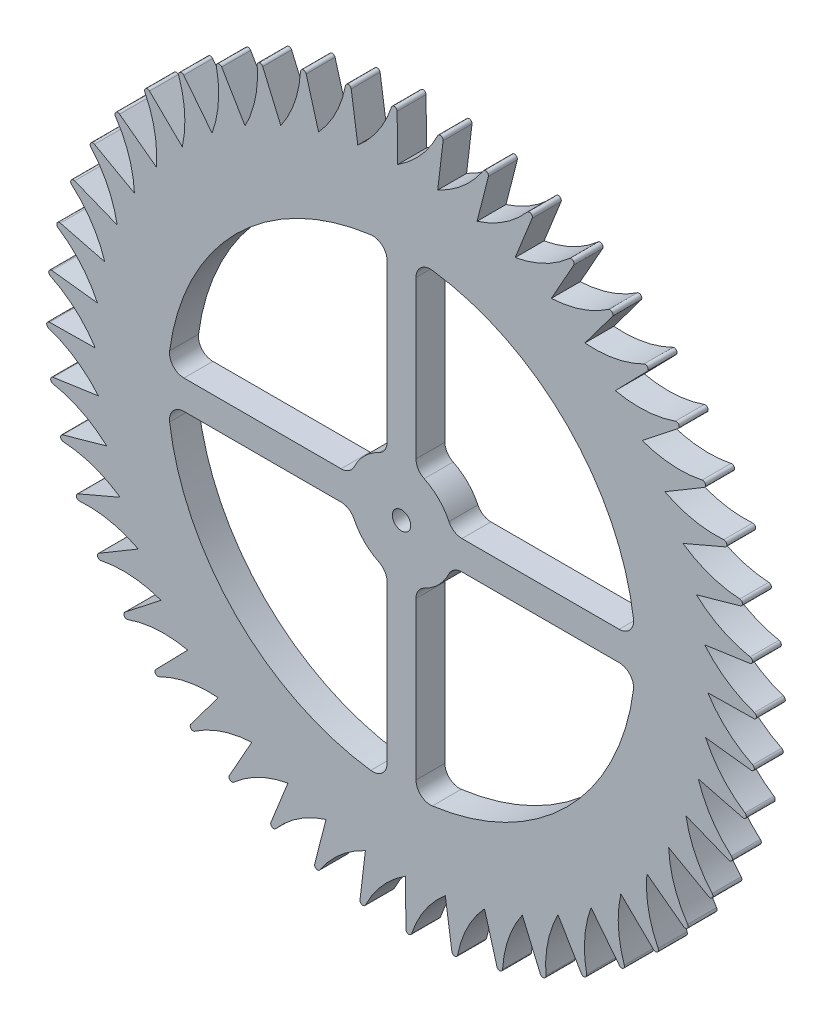
from build123d import *

# Parameters (mm, degrees)
SKETCH1_R           = 1.5875
BOSS_EXTRUDE1_DEPTH = 5
CUT_EXTRUDE1_DEPTH  = 6


with BuildPart() as part:
    # Sketch1 → Boss-Extrude1 (new body)
    with BuildSketch(Plane.XY):
        with BuildLine():
            Line((48.619657043, 86.443168783), (48.520234559, 94.35939249))
            ThreePointArc((48.520234559, 94.35939249), (48.096628031, 94.847248989), (47.545526606, 94.510004756))
            ThreePointArc((47.545526606, 94.510004756), (45.227938091, 89.801102483), (41.713355374, 85.903322927))
            Line((41.713355374, 85.903322927), (40.581508925, 93.738845005))
            ThreePointArc((40.581508925, 93.738845005), (40.097848359, 94.167236077), (39.595480889, 93.760943844))
            ThreePointArc((39.595480889, 93.760943844), (37.912354747, 88.789820879), (34.936602096, 84.466642269))
            Line((34.936602096, 84.466642269), (32.79169789, 92.087394762))
            ThreePointArc((32.79169789, 92.087394762), (32.256258852, 92.448990516), (31.811220983, 91.980602057))
            ThreePointArc((31.811220983, 91.980602057), (30.791355971, 86.832315692), (28.405349338, 82.157708811))
            Line((28.405349338, 82.157708811), (25.284087281, 89.433298531))
            ThreePointArc((25.284087281, 89.433298531), (24.70603128, 89.721911965), (24.325937734, 89.199441536))
            ThreePointArc((24.325937734, 89.199441536), (23.986784024, 83.962080378), (22.231348645, 79.016029046))
            Line((22.231348645, 79.016029046), (18.187134395, 85.821968637))
            ThreePointArc((18.187134395, 85.821968637), (17.576352131, 86.032661494), (17.267706414, 85.465048708))
            ThreePointArc((17.267706414, 85.465048708), (17.61506702, 80.228225458), (16.520238881, 75.095357986))
            Line((16.520238881, 75.095357986), (11.622270065, 81.315195933))
            ThreePointArc((11.622270065, 81.315195933), (10.989212192, 81.444363201), (10.757295317, 80.841320071))
            ThreePointArc((10.757295317, 80.841320071), (11.785226803, 75.694638227), (11.369738717, 70.4627794))
            Line((11.369738717, 70.4627794), (5.70182094, 75.990092552))
            ThreePointArc((5.70182094, 75.990092552), (5.057319253, 76.035524142), (4.906099382, 75.407368903))
            ThreePointArc((4.906099382, 75.407368903), (6.597013556, 70.438889619), (6.867974639, 65.197557991))
            Line((6.867974639, 65.197557991), (0.527087545, 69.937772487))
            ThreePointArc((0.527087545, 69.937772487), (-0.117830353, 69.898691053), (-0.185765805, 69.256171615))
            ThreePointArc((-0.185765805, 69.256171615), (2.139199045, 64.550906948), (3.091973078, 59.389783158))
            Line((3.091973078, 59.389783158), (-3.813388996, 63.261792614))
            ThreePointArc((-3.813388996, 63.261792614), (-4.447688381, 63.13886685), (-4.431177021, 62.492976899))
            ThreePointArc((-4.431177021, 62.492976899), (-1.511942286, 58.131435232), (0.106342469, 53.138827538))
            Line((0.106342469, 53.138827538), (-7.245341926, 56.076380799))
            ThreePointArc((-7.245341926, 56.076380799), (-7.858169761, 55.871713998), (-7.757494101, 55.23350489))
            ThreePointArc((-7.757494101, 55.23350489), (-4.293938399, 51.290313412), (-2.037832222, 46.551646715))
            Line((-2.037832222, 46.551646715), (-9.71004958, 48.504481431))
            ThreePointArc((-9.71004958, 48.504481431), (-10.290920209, 48.221575498), (-10.107802839, 47.601967168))
            ThreePointArc((-10.107802839, 47.601967168), (-6.159188567, 44.144594977), (-3.303863571, 39.740949179))
            Line((-3.303863571, 39.740949179), (-11.165340126, 40.675651806))
            ThreePointArc((-11.165340126, 40.675651806), (-11.704314691, 40.319347342), (-11.4418888, 39.72894146))
            ThreePointArc((-11.4418888, 39.72894146), (-7.075777843, 36.816545152), (-3.670089431, 32.823267854))
            Line((-3.670089431, 32.823267854), (-11.586313138, 32.72384537))
            ThreePointArc((-11.586313138, 32.72384537), (-12.074169637, 32.300238842), (-11.736925404, 31.749137417))
            ThreePointArc((-11.736925404, 31.749137417), (-7.028023131, 29.431548901), (-3.130243575, 25.916966184))
            Line((-3.130243575, 25.916966184), (-10.965765653, 24.785119736))
            ThreePointArc((-10.965765653, 24.785119736), (-11.394156725, 24.30145917), (-10.987864492, 23.799091699))
            ThreePointArc((-10.987864492, 23.799091699), (-6.016741527, 22.115965558), (-1.693562916, 19.140212907))
            Line((-1.693562916, 19.140212907), (-9.314315409, 16.995308701))
            ThreePointArc((-9.314315409, 16.995308701), (-9.675911164, 16.459869663), (-9.207522705, 16.014831793))
            ThreePointArc((-9.207522705, 16.014831793), (-4.05923634, 14.994966781), (0.615370541, 12.608960149))
            Line((0.615370541, 12.608960149), (-6.660219179, 9.487698091))
            ThreePointArc((-6.660219179, 9.487698091), (-6.948832613, 8.909642091), (-6.426362184, 8.529548545))
            ThreePointArc((-6.426362184, 8.529548545), (-1.189001025, 8.190394835), (3.757050306, 6.434959456))
            Line((3.757050306, 6.434959456), (-3.048889284, 2.390745206))
            ThreePointArc((-3.048889284, 2.390745206), (-3.259582142, 1.779962942), (-2.691969356, 1.471317224))
            ThreePointArc((-2.691969356, 1.471317224), (2.544853894, 1.818677831), (7.677721366, 0.723849692))
            Line((7.677721366, 0.723849692), (1.457883419, -4.174119124))
            ThreePointArc((1.457883419, -4.174119124), (1.328716151, -4.807176997), (1.931759281, -5.039093873))
            ThreePointArc((1.931759281, -5.039093873), (7.078441125, -4.011162386), (12.310299952, -4.426650472))
            Line((12.310299952, -4.426650472), (6.7829868, -10.09456825))
            ThreePointArc((6.7829868, -10.09456825), (6.73755521, -10.739069936), (7.365710449, -10.890289807))
            ThreePointArc((7.365710449, -10.890289807), (12.334189733, -9.199375634), (17.575521361, -8.92841455))
            Line((17.575521361, -8.92841455), (12.835306865, -15.269301644))
            ThreePointArc((12.835306865, -15.269301644), (12.874388299, -15.914219542), (13.516907737, -15.982154995))
            ThreePointArc((13.516907737, -15.982154995), (18.222172404, -13.657190144), (23.383296194, -12.704416111))
            Line((23.383296194, -12.704416111), (19.511286738, -19.609778185))
            ThreePointArc((19.511286738, -19.609778185), (19.634212503, -20.244077571), (20.280102453, -20.22756621))
            ThreePointArc((20.280102453, -20.22756621), (24.64164412, -17.308331476), (29.634251814, -15.690046721))
            Line((29.634251814, -15.690046721), (26.696698553, -23.041731116))
            ThreePointArc((26.696698553, -23.041731116), (26.901365354, -23.65455895), (27.539574462, -23.55388329))
            ThreePointArc((27.539574462, -23.55388329), (31.482765941, -20.090327588), (36.221432637, -17.834221412))
            Line((36.221432637, -17.834221412), (34.268597922, -25.506438769))
            ThreePointArc((34.268597922, -25.506438769), (34.551503854, -26.087309398), (35.171112184, -25.904192028))
            ThreePointArc((35.171112184, -25.904192028), (38.628484375, -21.955577756), (43.032130173, -19.100252761))
            Line((43.032130173, -19.100252761), (42.097427547, -26.961729315))
            ThreePointArc((42.097427547, -26.961729315), (42.453732011, -27.500703881), (43.044137892, -27.238277989))
            ThreePointArc((43.044137892, -27.238277989), (45.9565342, -22.872167032), (49.949811498, -19.46647862))
            Line((49.949811498, -19.46647862), (50.049233982, -27.382702327))
            ThreePointArc((50.049233982, -27.382702327), (50.47284051, -27.870558826), (51.023941935, -27.533314593))
            ThreePointArc((51.023941935, -27.533314593), (53.341530451, -22.82441232), (56.856113168, -18.926632765))
            Line((56.856113168, -18.926632765), (57.987959616, -26.762154842))
            ThreePointArc((57.987959616, -26.762154842), (58.471620182, -27.190545914), (58.973987653, -26.784253681))
            ThreePointArc((58.973987653, -26.784253681), (60.657113794, -21.813130716), (63.632866445, -17.489952106))
            Line((63.632866445, -17.489952106), (65.777770651, -25.110704599))
            ThreePointArc((65.777770651, -25.110704599), (66.31320969, -25.472300354), (66.758247559, -25.003911894))
            ThreePointArc((66.758247559, -25.003911894), (67.778112571, -19.855625529), (70.164119203, -15.181018648))
            Line((70.164119203, -15.181018648), (73.285381261, -22.456608368))
            ThreePointArc((73.285381261, -22.456608368), (73.863437261, -22.745221803), (74.243530808, -22.222751373))
            ThreePointArc((74.243530808, -22.222751373), (74.582684518, -16.985390215), (76.338119896, -12.039338883))
            Line((76.338119896, -12.039338883), (80.382334147, -18.845278474))
            ThreePointArc((80.382334147, -18.845278474), (80.99311641, -19.055971331), (81.301762128, -18.488358545))
            ThreePointArc((81.301762128, -18.488358545), (80.954401522, -13.251535296), (82.04922966, -8.118667823))
            Line((82.04922966, -8.118667823), (86.947198476, -14.338505771))
            ThreePointArc((86.947198476, -14.338505771), (87.58025635, -14.467673038), (87.812173225, -13.864629908))
            ThreePointArc((87.812173225, -13.864629908), (86.784241738, -8.717948065), (87.199729824, -3.486089237))
            Line((87.199729824, -3.486089237), (92.867647602, -9.013402389))
            ThreePointArc((92.867647602, -9.013402389), (93.512149289, -9.058833979), (93.663369159, -8.43067874))
            ThreePointArc((93.663369159, -8.43067874), (91.972454986, -3.462199456), (91.701493902, 1.779132172))
            Line((91.701493902, 1.779132172), (98.042380997, -2.961082325))
            ThreePointArc((98.042380997, -2.961082325), (98.687298895, -2.92200089), (98.755234347, -2.279481452))
            ThreePointArc((98.755234347, -2.279481452), (96.430269496, 2.425783214), (95.477495463, 7.586907005))
            Line((95.477495463, 7.586907005), (102.382857538, 3.714897548))
            ThreePointArc((102.382857538, 3.714897548), (103.017156923, 3.837823313), (103.000645562, 4.483713264))
            ThreePointArc((103.000645562, 4.483713264), (100.081410828, 8.84525493), (98.463126073, 13.837862625))
            Line((98.463126073, 13.837862625), (105.814810468, 10.900309363))
            ThreePointArc((105.814810468, 10.900309363), (106.427638302, 11.104976165), (106.326962642, 11.743185273))
            ThreePointArc((106.326962642, 11.743185273), (102.86340694, 15.686376751), (100.607300764, 20.425043448))
            Line((100.607300764, 20.425043448), (108.279518122, 18.472208732))
            ThreePointArc((108.279518122, 18.472208732), (108.86038875, 18.755114664), (108.67727138, 19.374722994))
            ThreePointArc((108.67727138, 19.374722994), (104.728657108, 22.832095186), (101.873332113, 27.235740984))
            Line((101.873332113, 27.235740984), (109.734808667, 26.301038357))
            ThreePointArc((109.734808667, 26.301038357), (110.273783233, 26.657342821), (110.011357341, 27.247748703))
            ThreePointArc((110.011357341, 27.247748703), (105.645246385, 30.160145011), (102.239557972, 34.153422309))
            Line((102.239557972, 34.153422309), (110.15578168, 34.252844793))
            ThreePointArc((110.15578168, 34.252844793), (110.643638178, 34.676451321), (110.306393945, 35.227552746))
            ThreePointArc((110.306393945, 35.227552746), (105.597491673, 37.545141261), (101.699712117, 41.059723979))
            Line((101.699712117, 41.059723979), (109.535234194, 42.191570427))
            ThreePointArc((109.535234194, 42.191570427), (109.963625266, 42.675230993), (109.557333034, 43.177598464))
            ThreePointArc((109.557333034, 43.177598464), (104.586210069, 44.860724605), (100.263031458, 47.836477256))
            Line((100.263031458, 47.836477256), (107.883783951, 49.981381462))
            ThreePointArc((107.883783951, 49.981381462), (108.245379706, 50.5168205), (107.776991246, 50.961858369))
            ThreePointArc((107.776991246, 50.961858369), (102.628704881, 51.981723382), (97.954098, 54.367730014))
            Line((97.954098, 54.367730014), (105.229687721, 57.488992072))
            ThreePointArc((105.229687721, 57.488992072), (105.518301155, 58.067048072), (104.995830725, 58.447141618))
            ThreePointArc((104.995830725, 58.447141618), (99.758469567, 58.786295328), (94.812418236, 60.541730707))
            Line((94.812418236, 60.541730707), (101.618357826, 64.585944957))
            ThreePointArc((101.618357826, 64.585944957), (101.829050684, 65.196727221), (101.261437898, 65.505372939))
            ThreePointArc((101.261437898, 65.505372939), (96.024614648, 65.158012332), (90.891747176, 66.252840471))
            Line((90.891747176, 66.252840471), (97.111585123, 71.150809287))
            ThreePointArc((97.111585123, 71.150809287), (97.240752391, 71.78386716), (96.63770926, 72.015784035))
            ThreePointArc((96.63770926, 72.015784035), (91.491027417, 70.987852549), (86.259168589, 71.403340635))
            Line((86.259168589, 71.403340635), (91.786481741, 77.071258412))
            ThreePointArc((91.786481741, 77.071258412), (91.831913332, 77.715760099), (91.203758092, 77.86697997))
            ThreePointArc((91.203758092, 77.86697997), (86.235278808, 76.176065796), (80.99394718, 75.905104713))
            Line((80.99394718, 75.905104713), (85.734161677, 82.245991807))
            ThreePointArc((85.734161677, 82.245991807), (85.695080242, 82.890909705), (85.052560805, 82.958845157))
            ThreePointArc((85.052560805, 82.958845157), (80.347296138, 80.633880307), (75.186172347, 79.681106274))
            Line((75.186172347, 79.681106274), (79.058181804, 86.586468348))
            ThreePointArc((79.058181804, 86.586468348), (78.935256039, 87.220767734), (78.289366088, 87.204256373))
            ThreePointArc((78.289366088, 87.204256373), (73.927824422, 84.285021639), (68.935216727, 82.666736883))
            Line((68.935216727, 82.666736883), (71.872769989, 90.018421279))
            ThreePointArc((71.872769989, 90.018421279), (71.668103187, 90.631249113), (71.02989408, 90.530573453))
            ThreePointArc((71.02989408, 90.530573453), (67.086702601, 87.067017751), (62.348035904, 84.810911574))
            Line((62.348035904, 84.810911574), (64.30087062, 92.483128932))
            ThreePointArc((64.30087062, 92.483128932), (64.017964688, 93.063999561), (63.398356358, 92.880882191))
            ThreePointArc((63.398356358, 92.880882191), (59.940984166, 88.932267919), (55.537338369, 86.076942923))
            Line((55.537338369, 86.076942923), (56.472040995, 93.938419478))
            ThreePointArc((56.472040995, 93.938419478), (56.115736531, 94.477394044), (55.525330649, 94.214968152))
            ThreePointArc((55.525330649, 94.214968152), (52.612934341, 89.848857195), (48.619657043, 86.443168783))
        make_face()
        with Locations((49.284734271, 33.488345081)):
            Circle(SKETCH1_R, mode=Mode.SUBTRACT)
    extrude(amount=BOSS_EXTRUDE1_DEPTH)

    # Sketch2 → Cut-Extrude1 (cut, through all)
    with BuildSketch(Plane.XY.offset(5)):
        with BuildLine():
            Line((51.784734271, 43.941581721), (51.784734271, 71.116601499))
            ThreePointArc((51.784734271, 71.116601499), (52.637502756, 72.997194048), (54.614036939, 73.59481855))
            ThreePointArc((54.614036939, 73.59481855), (77.893567531, 62.097178341), (89.391207739, 38.81764775))
            ThreePointArc((89.391207739, 38.81764775), (88.793583237, 36.841113566), (86.912990688, 35.988345081))
            Line((86.912990688, 35.988345081), (59.737970911, 35.988345081))
            ThreePointArc((59.737970911, 35.988345081), (58.405092752, 36.373295244), (57.482687925, 37.40959643))
            ThreePointArc((57.482687925, 37.40959643), (55.710567145, 39.914177955), (53.205985619, 41.686298735))
            ThreePointArc((53.205985619, 41.686298735), (52.169684433, 42.608703563), (51.784734271, 43.941581721))
        make_face()
        with BuildLine():
            Line((59.737970911, 30.988345081), (86.912990688, 30.988345081))
            ThreePointArc((86.912990688, 30.988345081), (88.793583237, 30.135576596), (89.391207739, 28.159042413))
            ThreePointArc((89.391207739, 28.159042413), (77.893567531, 4.879511821), (54.614036939, -6.618128387))
            ThreePointArc((54.614036939, -6.618128387), (52.637502756, -6.020503885), (51.784734271, -4.139911336))
            Line((51.784734271, -4.139911336), (51.784734271, 23.035108441))
            ThreePointArc((51.784734271, 23.035108441), (52.169684433, 24.3679866), (53.205985619, 25.290391427))
            ThreePointArc((53.205985619, 25.290391427), (55.710567145, 27.062512207), (57.482687925, 29.567093733))
            ThreePointArc((57.482687925, 29.567093733), (58.405092752, 30.603394919), (59.737970911, 30.988345081))
        make_face()
        with BuildLine():
            Line((46.784734271, 23.035108441), (46.784734271, -4.139911336))
            ThreePointArc((46.784734271, -4.139911336), (45.931965786, -6.020503885), (43.955431602, -6.618128387))
            ThreePointArc((43.955431602, -6.618128387), (20.675901011, 4.879511821), (9.178260802, 28.159042413))
            ThreePointArc((9.178260802, 28.159042413), (9.775885304, 30.135576596), (11.656477854, 30.988345081))
            Line((11.656477854, 30.988345081), (38.831497631, 30.988345081))
            ThreePointArc((38.831497631, 30.988345081), (40.164375789, 30.603394919), (41.086780617, 29.567093733))
            ThreePointArc((41.086780617, 29.567093733), (42.858901397, 27.062512207), (45.363482922, 25.290391427))
            ThreePointArc((45.363482922, 25.290391427), (46.399784108, 24.3679866), (46.784734271, 23.035108441))
        make_face()
        with BuildLine():
            Line((38.831497631, 35.988345081), (11.656477854, 35.988345081))
            ThreePointArc((11.656477854, 35.988345081), (9.775885304, 36.841113566), (9.178260802, 38.81764775))
            ThreePointArc((9.178260802, 38.81764775), (20.675901011, 62.097178341), (43.955431602, 73.59481855))
            ThreePointArc((43.955431602, 73.59481855), (45.931965786, 72.997194048), (46.784734271, 71.116601499))
            Line((46.784734271, 71.116601499), (46.784734271, 43.941581721))
            ThreePointArc((46.784734271, 43.941581721), (46.399784108, 42.608703563), (45.363482922, 41.686298735))
            ThreePointArc((45.363482922, 41.686298735), (42.858901397, 39.914177955), (41.086780617, 37.40959643))
            ThreePointArc((41.086780617, 37.40959643), (40.164375789, 36.373295244), (38.831497631, 35.988345081))
        make_face()
    extrude(amount=-CUT_EXTRUDE1_DEPTH, mode=Mode.SUBTRACT)


solid = part.part
